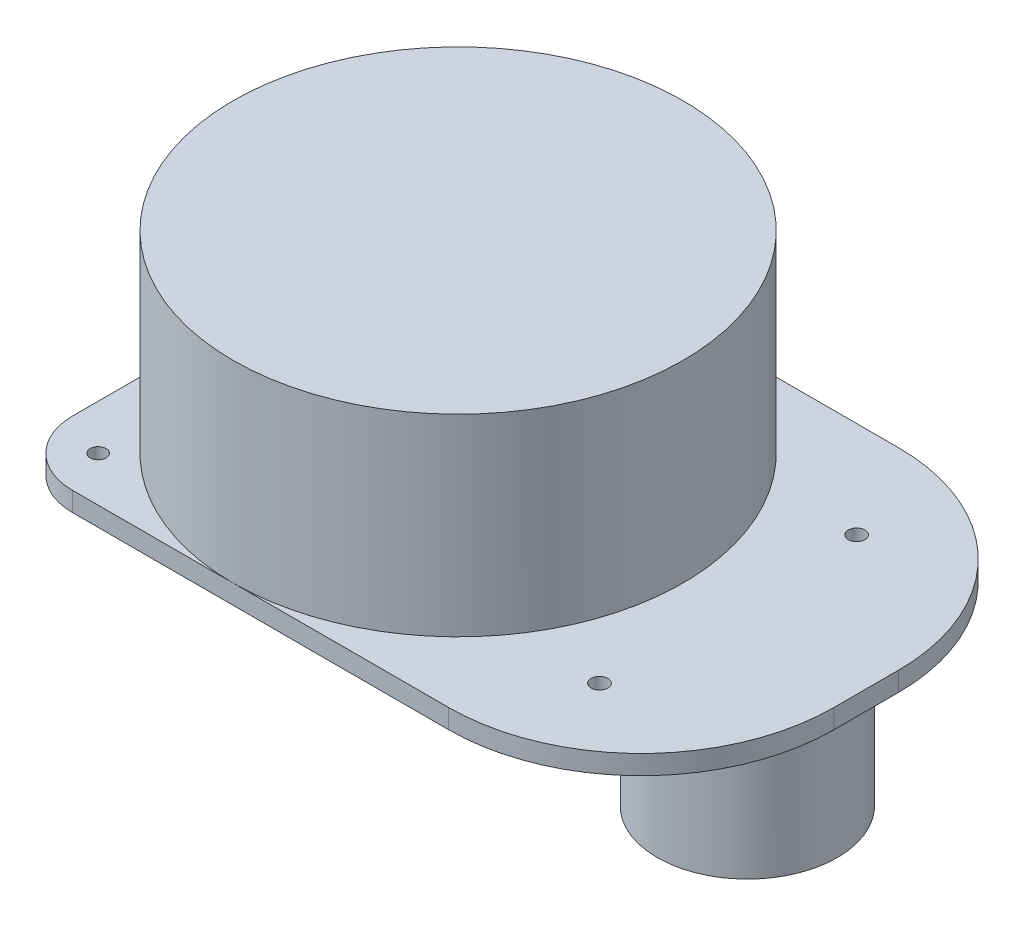
from build123d import *

# Parameters (mm, degrees)
SKETCH_1_R          = 35
EXTRUDE_1_DEPTH     = 30
SKETCH_2_W          = 98.5
SKETCH_2_H          = 70
EXTRUDE_2_DEPTH     = 3
FILLET_1_R          = 10
FILLET_2_R          = 30
FILLET_3_R          = 30
SKETCH_3_R          = 1.3
SKETCH_3_R_2        = 1.252848492
CUT_EXTRUDE_1_DEPTH = 3
SKETCH_4_R          = 14
EXTRUDE_3_DEPTH     = 22


with BuildPart() as part:
    # 스케치1 → 보스-돌출1 (new body)
    with BuildSketch(Plane(origin=(0, 0, 0), x_dir=(1, 0, 0), z_dir=(0, 1, 0))):
        Circle(SKETCH_1_R)
    extrude(amount=EXTRUDE_1_DEPTH)

    # 스케치2 → 보스-돌출2 (add)
    with BuildSketch(Plane.XZ):
        with Locations((14.25, 0)):
            Rectangle(SKETCH_2_W, SKETCH_2_H)
    extrude(amount=EXTRUDE_2_DEPTH)

    # 필렛1
    fillet_1_edges = [part.edges().sort_by_distance(p)[0] for p in [
        (-35, -1.5, 35),
        (-35, -1.5, -35),
    ]]
    fillet(fillet_1_edges, radius=FILLET_1_R)

    # 필렛2
    fillet_2_edges = [part.edges().sort_by_distance(p)[0] for p in [
        (63.5, -1.5, -35),
    ]]
    fillet(fillet_2_edges, radius=FILLET_2_R)

    # 필렛3
    fillet_3_edges = [part.edges().sort_by_distance(p)[0] for p in [
        (63.5, -1.5, 35),
    ]]
    fillet(fillet_3_edges, radius=FILLET_3_R)

    # 스케치3 → 컷-돌출1 (cut)
    with BuildSketch(Plane(origin=(0, 0, 0), x_dir=(1, 0, 0), z_dir=(0, 1, 0))):
        with Locations((-28, 28)):
            Circle(SKETCH_3_R)
        with Locations((-28, -28.00420951)):
            Circle(SKETCH_3_R_2)
        with Locations((42, 20)):
            Circle(SKETCH_3_R)
        with Locations((42, -20)):
            Circle(SKETCH_3_R)
    extrude(amount=-CUT_EXTRUDE_1_DEPTH, mode=Mode.SUBTRACT)

    # 스케치4 → 보스-돌출3 (add)
    with BuildSketch(Plane.XZ.offset(3)):
        with Locations((45, 0)):
            Circle(SKETCH_4_R)
    extrude(amount=EXTRUDE_3_DEPTH)


solid = part.part
